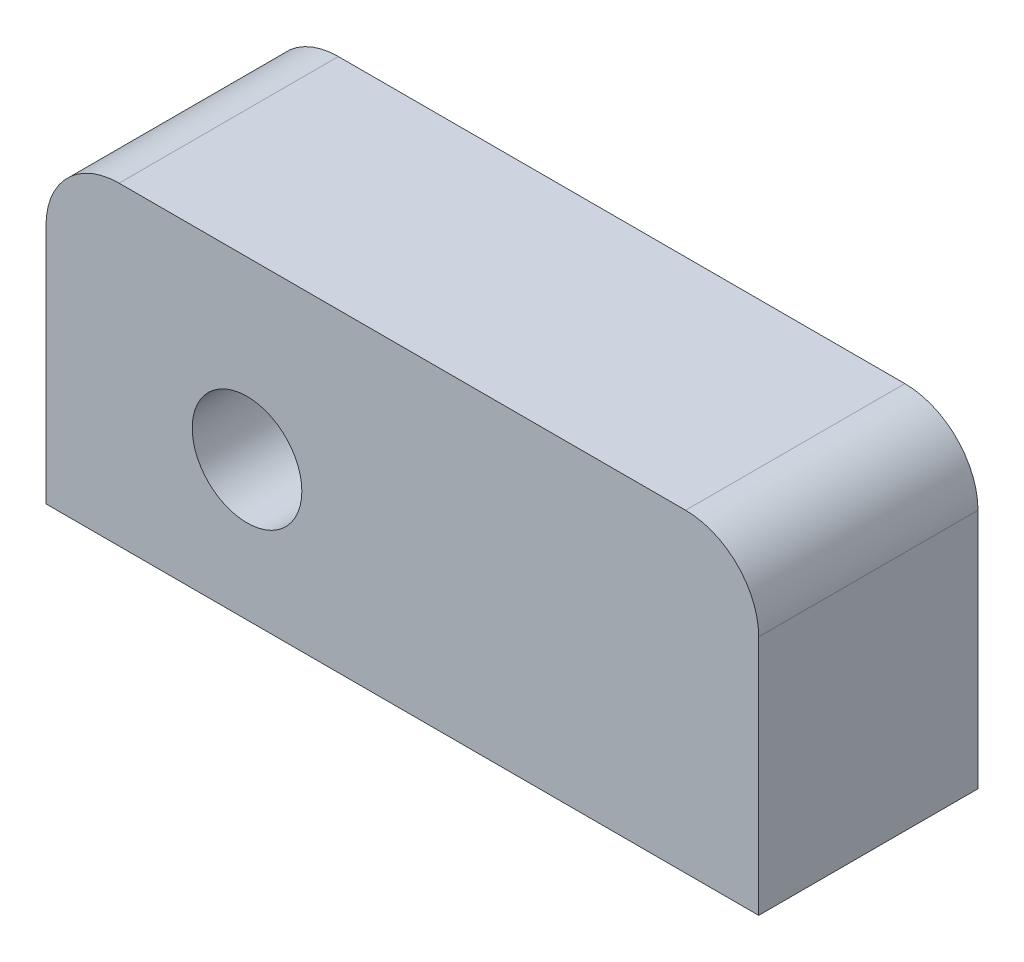
from build123d import *

# Parameters (mm, degrees)
SZKIC1_W                    = 97.5
SZKIC1_H                    = 43
DODANIE_WYCI_GNI_CIE1_DEPTH = 30
ZAOKR_GLENIE1_R             = 10
ZAOKR_GLENIE2_R             = 10
SZKIC2_R                    = 7.5
WYTNIJ_WYCI_GNI_CIE1_DEPTH  = 30


with BuildPart() as part:
    # Szkic1 → Dodanie-wyciągnięcie1 (new body)
    with BuildSketch(Plane.XY):
        Rectangle(SZKIC1_W, SZKIC1_H)
    extrude(amount=DODANIE_WYCI_GNI_CIE1_DEPTH)

    # Zaokrąglenie1
    zaokr_glenie1_edges = [part.edges().sort_by_distance(p)[0] for p in [
        (-48.75, 21.5, 15),
    ]]
    fillet(zaokr_glenie1_edges, radius=ZAOKR_GLENIE1_R)

    # Zaokrąglenie2
    zaokr_glenie2_edges = [part.edges().sort_by_distance(p)[0] for p in [
        (48.75, 21.5, 15),
    ]]
    fillet(zaokr_glenie2_edges, radius=ZAOKR_GLENIE2_R)

    # Szkic2 → Wytnij-wyciągnięcie1 (cut)
    with BuildSketch(Plane.XY.offset(30)):
        with Locations((-21.25, -2.5)):
            Circle(SZKIC2_R)
    extrude(amount=-WYTNIJ_WYCI_GNI_CIE1_DEPTH, mode=Mode.SUBTRACT)


solid = part.part
